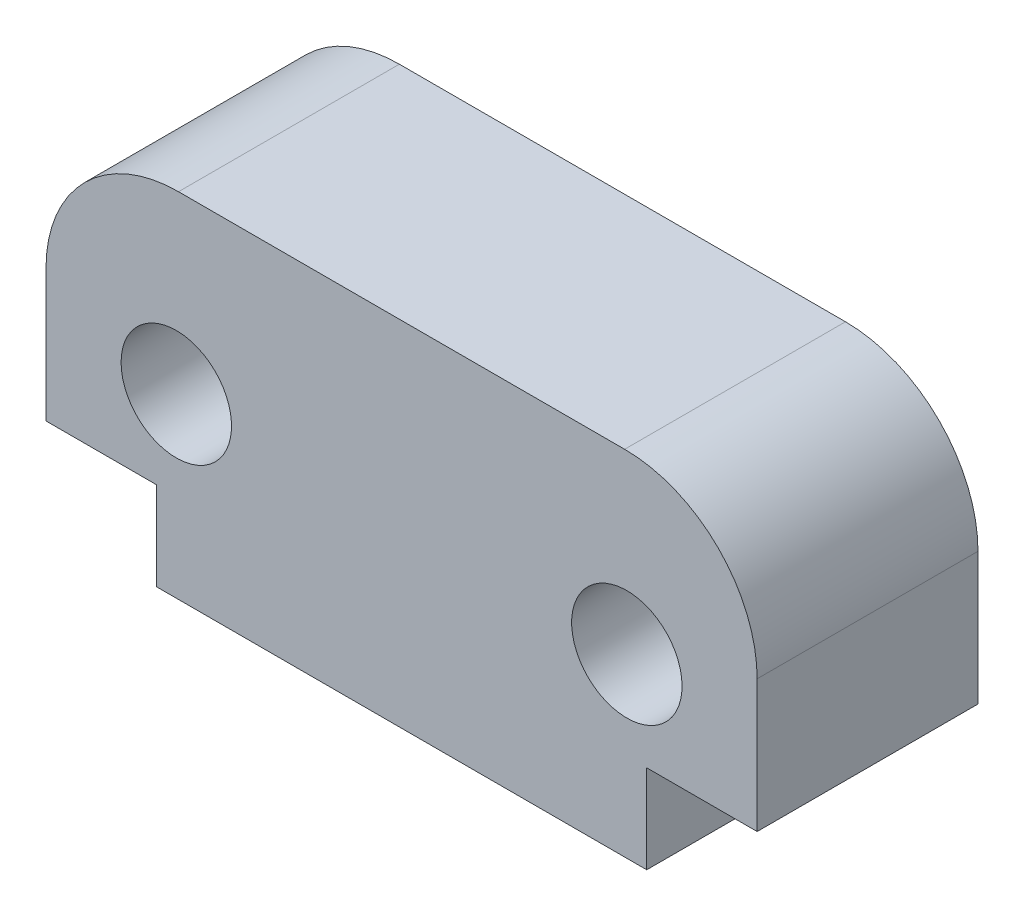
from build123d import *

# Parameters (mm, degrees)
MODEL_R             = 1.25
BOSS_EXTRUDE1_DEPTH = 5


with BuildPart() as part:
    # Model → Boss-Extrude1 (new body)
    with BuildSketch(Plane.XY):
        with BuildLine():
            Line((0, 2), (-2.5, 2))
            Line((-2.5, 2), (-2.5, 4.995169548))
            ThreePointArc((-2.5, 4.995169548), (-1.621320344, 7.116489891), (0.5, 7.995169548))
            Line((0.5, 7.995169548), (10.6, 7.995169548))
            ThreePointArc((10.6, 7.995169548), (12.721320344, 7.116489891), (13.6, 4.995169548))
            Line((13.6, 4.995169548), (13.6, 2))
            Line((13.6, 2), (11.1, 2))
            Line((11.1, 2), (11.1, 0))
            Line((11.1, 0), (0, 0))
            Line((0, 0), (0, 2))
        make_face()
        with Locations((0.45, 4)):
            Circle(MODEL_R, mode=Mode.SUBTRACT)
        with Locations((10.65, 4)):
            Circle(MODEL_R, mode=Mode.SUBTRACT)
    extrude(amount=BOSS_EXTRUDE1_DEPTH)


solid = part.part
